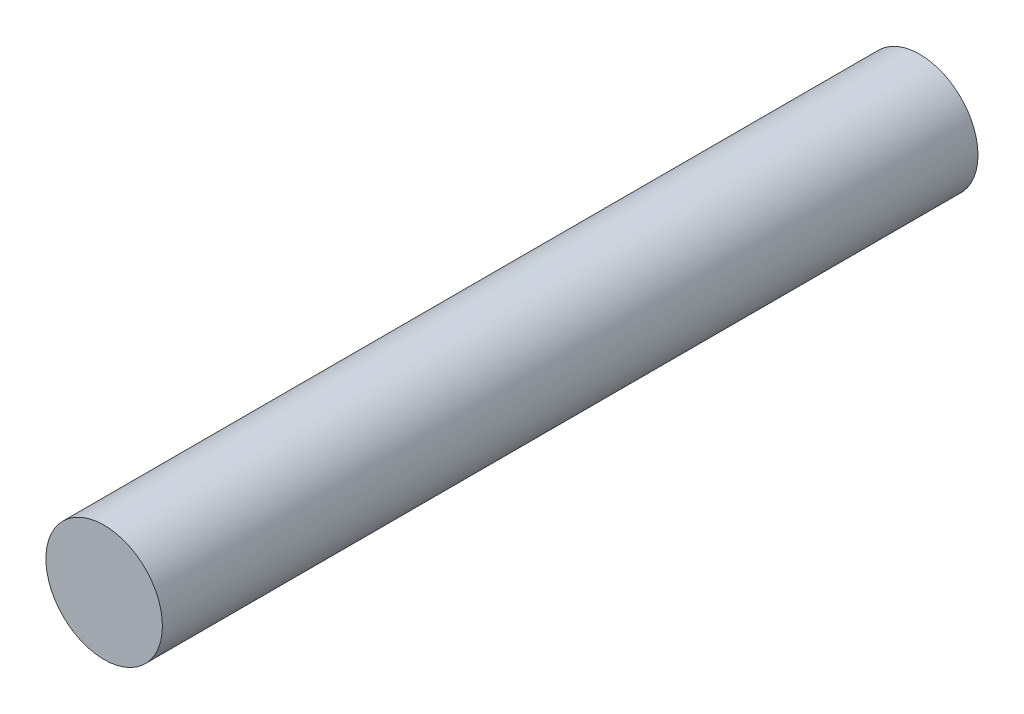
from build123d import *

# Parameters (mm, degrees)
SKETCH1_R           = 1
BOSS_EXTRUDE1_DEPTH = 14


with BuildPart() as part:
    # Sketch1 → Boss-Extrude1 (new body)
    with BuildSketch(Plane.XY):
        Circle(SKETCH1_R)
    extrude(amount=BOSS_EXTRUDE1_DEPTH)


solid = part.part
